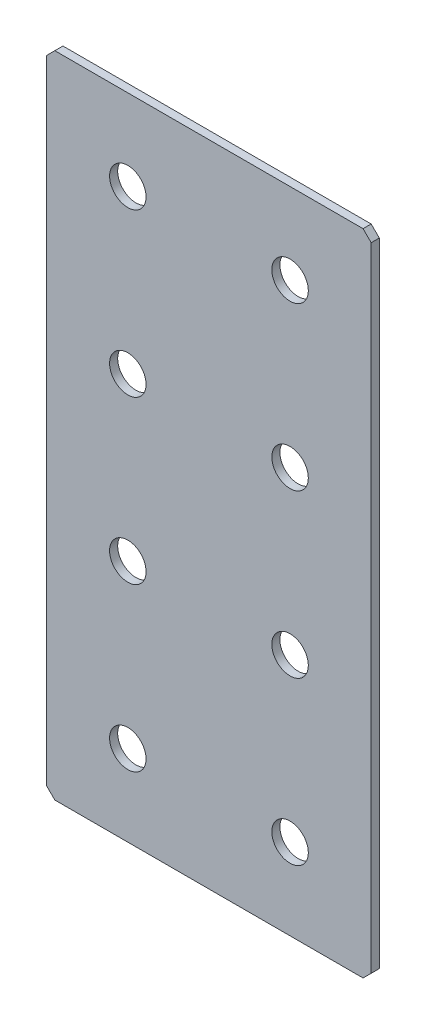
from build123d import *

# Parameters (mm, degrees)
SKETCH_1_W        = 80
SKETCH_1_H        = 160
EXTRUDE_1_DEPTH   = 2
CHAMFER_1_SIZE    = 2
HOLE_WIZARD_M81_D = 9


with BuildPart() as part:
    # Эскиз1 → Бобышка-Вытянуть1 (new body)
    with BuildSketch(Plane.XY):
        Rectangle(SKETCH_1_W, SKETCH_1_H)
    extrude(amount=EXTRUDE_1_DEPTH)

    # Фаска1
    chamfer_1_edges = [part.edges().sort_by_distance(p)[0] for p in [
        (40, -80, 1),
        (-40, -80, 1),
        (-40, 80, 1),
        (40, 80, 1),
    ]]
    chamfer(chamfer_1_edges, length=CHAMFER_1_SIZE)

    # Отверстие с зазором M81 (through all)
    with Locations(Plane.XY.offset(2)):
        with Locations((-20, 20), (20, 20), (-20, -20), (20, -20), (-20, 60), (20, 60), (20, -60), (-20, -60)):
            Hole(HOLE_WIZARD_M81_D / 2)


solid = part.part
